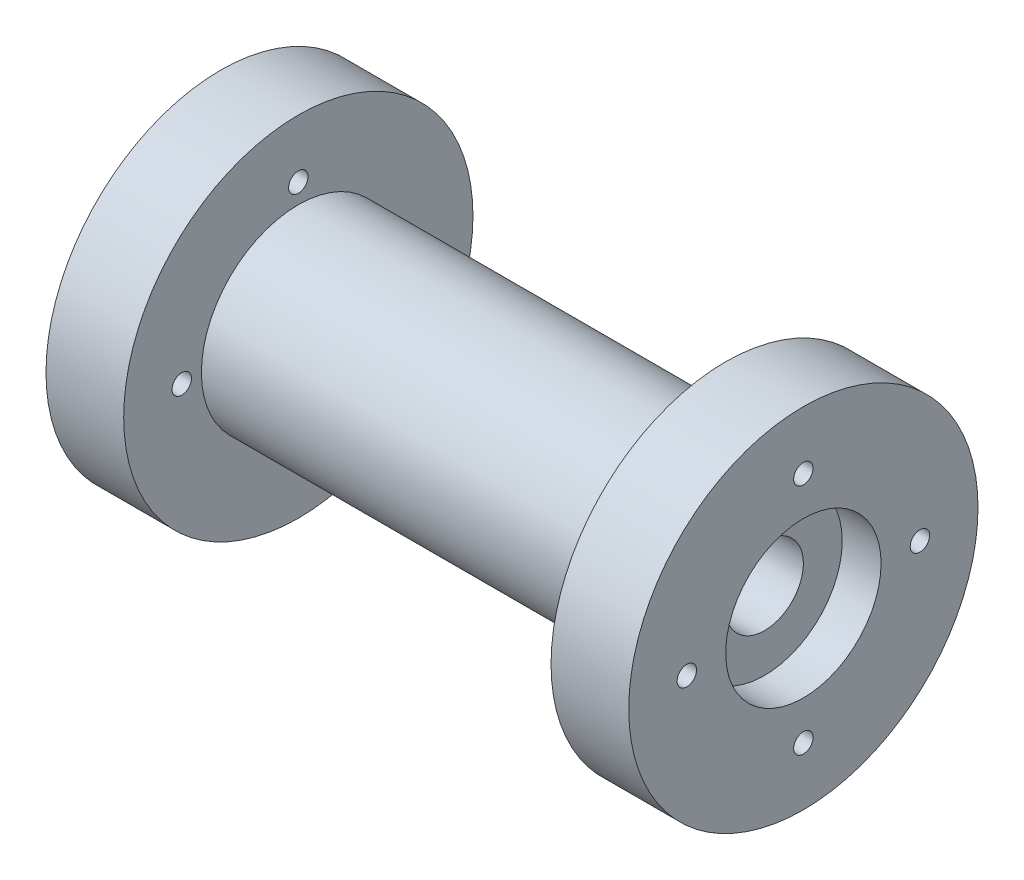
from build123d import *

# Parameters (mm, degrees)
SKETCH2_R          = 1.25
CUT_EXTRUDE1_DEPTH = 76
SKETCH3_R          = 10
CUT_EXTRUDE2_DEPTH = 5
SKETCH4_R          = 10
CUT_EXTRUDE3_DEPTH = 5


with BuildPart() as part:
    # Sketch1 → Revolve1 (revolve)
    with BuildSketch(Plane.XY):
        Polygon((0, 5), (0, 22.473684211), (10, 22.473684211), (10, 12.473684211), (65, 12.473684211), (65, 22.473684211), (75, 22.473684211), (75, 5), align=None)
    revolve(axis=Axis((0, 0, 0), (1, 0, 0)))

    # Sketch2 → Cut-Extrude1 (cut, through all)
    with BuildSketch(Plane.ZY):
        with Locations((0, 15)):
            Circle(SKETCH2_R)
        with Locations((-15, 0)):
            Circle(SKETCH2_R)
        with Locations((0, -15)):
            Circle(SKETCH2_R)
        with Locations((15, 0)):
            Circle(SKETCH2_R)
    extrude(amount=-CUT_EXTRUDE1_DEPTH, mode=Mode.SUBTRACT)

    # Sketch3 → Cut-Extrude2 (cut)
    with BuildSketch(Plane.ZY):
        Circle(SKETCH3_R)
    extrude(amount=-CUT_EXTRUDE2_DEPTH, mode=Mode.SUBTRACT)

    # Sketch4 → Cut-Extrude3 (cut)
    with BuildSketch(Plane(origin=(75, 0, 0), x_dir=(0, 0, -1), z_dir=(1, 0, 0))):
        Circle(SKETCH4_R)
    extrude(amount=-CUT_EXTRUDE3_DEPTH, mode=Mode.SUBTRACT)


solid = part.part
